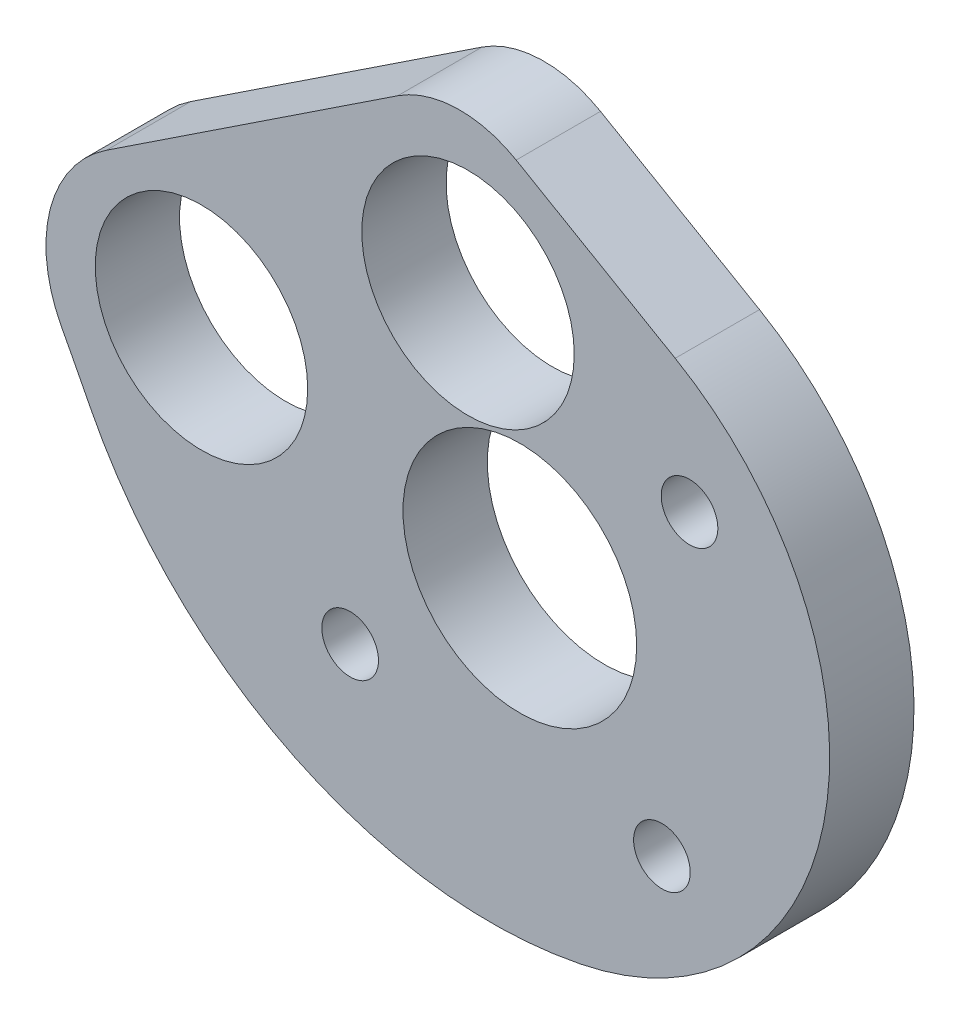
from build123d import *

# Parameters (mm, degrees)
SKETCH1_R           = 6.00075
SKETCH1_R_2         = 1.6
SKETCH1_R_3         = 6.6
BOSS_EXTRUDE1_DEPTH = 4.7625


with BuildPart() as part:
    # Sketch1 → Boss-Extrude1 (new body)
    with BuildSketch(Plane.XY):
        with BuildLine():
            Line((179.148086511, 103.607144631), (195.603327806, 114.500302414))
            ThreePointArc((195.603327806, 114.500302414), (198.919543637, 115.552562907), (202.292483355, 114.699440851))
            Line((202.292483355, 114.699440851), (211.27381454, 109.494480567))
            ThreePointArc((211.27381454, 109.494480567), (219.765287832, 91.502488859), (205.940797496, 77.195135812))
            Line((205.940797496, 77.195135812), (205.873802068, 77.181697321))
            ThreePointArc((205.873802068, 77.181697321), (189.799923624, 79.228940232), (178.234639917, 90.578168601))
            ThreePointArc((178.234639917, 90.578168601), (177.435417915, 92.133945768), (176.622616151, 93.682671597))
            ThreePointArc((176.622616151, 93.682671597), (175.969639562, 99.132397301), (179.148086511, 103.607144631))
        make_face()
        with Locations((184.517388009, 97.618855822)):
            Circle(SKETCH1_R, mode=Mode.SUBTRACT)
        with Locations((199.571302743, 106.841754978)):
            Circle(SKETCH1_R, mode=Mode.SUBTRACT)
        with Locations((212.083037321, 102.378153756)):
            Circle(SKETCH1_R_2, mode=Mode.SUBTRACT)
        with Locations((210.523861298, 84.769378384)):
            Circle(SKETCH1_R_2, mode=Mode.SUBTRACT)
        with Locations((192.915085926, 86.328554406)):
            Circle(SKETCH1_R_2, mode=Mode.SUBTRACT)
        with Locations((202.499061623, 94.353354081)):
            Circle(SKETCH1_R_3, mode=Mode.SUBTRACT)
    extrude(amount=BOSS_EXTRUDE1_DEPTH)


solid = part.part
